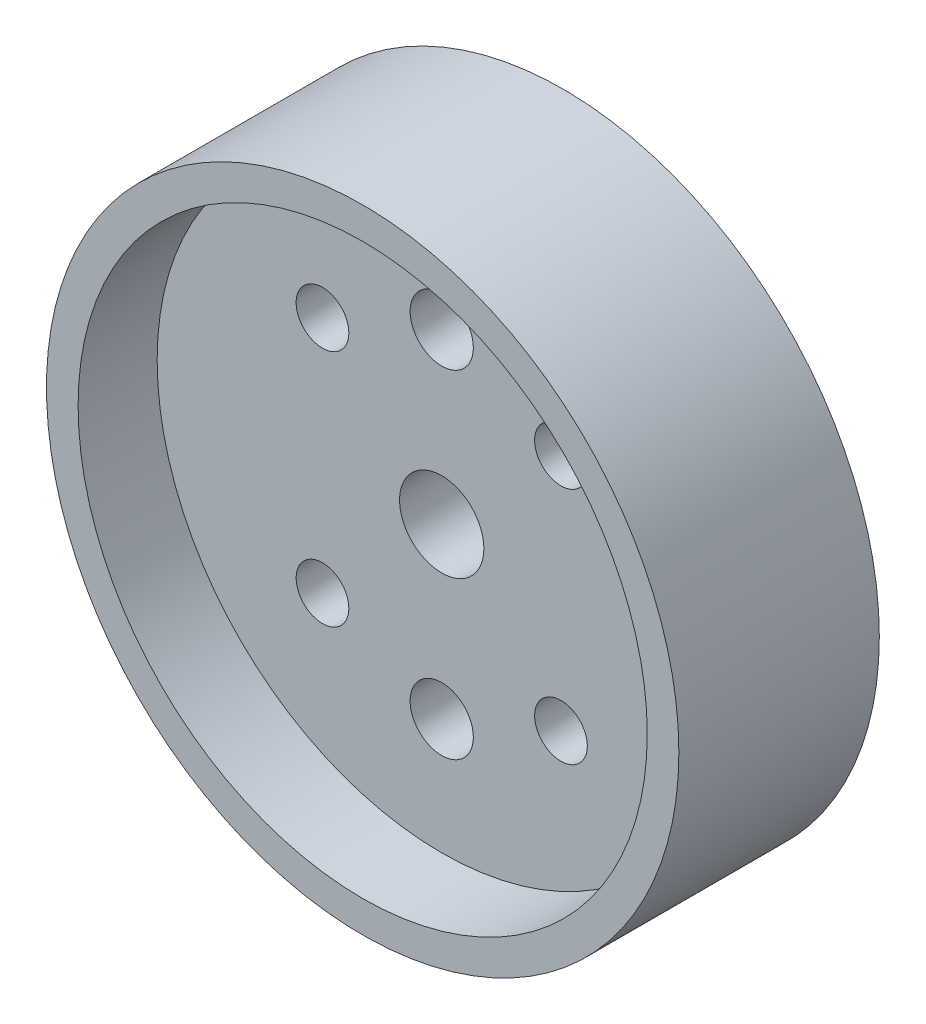
from build123d import *

# Parameters (mm, degrees)
ESBO_O1_R                = 30
RESSALTO_EXTRUS_O1_DEPTH = 19.02
ESBO_O2_R                = 26
CORTE_EXTRUS_O1_DEPTH    = 7
ESBO_O7_R                = 27
CORTE_EXTRUS_O4_DEPTH    = 7.5
ESBO_O13_R               = 3
ESBO_O13_R_2             = 2.5
CORTE_EXTRUS_O10_DEPTH   = 12.52
ESBO_O14_R               = 4
CORTE_EXTRUS_O11_DEPTH   = 12.52
ESBO_O16_R               = 5.25
ESBO_O16_R_2             = 4.5
CORTE_EXTRUS_O12_DEPTH   = 6


with BuildPart() as part:
    # Esboço1 → Ressalto-extrusão1 (new body)
    with BuildSketch(Plane.XY):
        Circle(ESBO_O1_R)
    extrude(amount=RESSALTO_EXTRUS_O1_DEPTH)

    # Esboço2 → Corte-extrusão1 (cut)
    with BuildSketch(Plane.XY.offset(19.02)):
        Circle(ESBO_O2_R)
    extrude(amount=-CORTE_EXTRUS_O1_DEPTH, mode=Mode.SUBTRACT)

    # Esboço7 → Corte-extrusão4 (cut)
    with BuildSketch(Plane.XY.offset(19.02)):
        Circle(ESBO_O7_R)
    extrude(amount=-CORTE_EXTRUS_O4_DEPTH, mode=Mode.SUBTRACT)

    # Esboço13 → Corte-extrusão10 (cut, through all)
    with BuildSketch(Plane.XY.offset(11.52)):
        with Locations((0, 16)):
            Circle(ESBO_O13_R)
        with Locations((0, -16)):
            Circle(ESBO_O13_R)
        with Locations((-11.313708499, 11.313708499)):
            Circle(ESBO_O13_R_2)
        with Locations((11.313708499, 11.313708499)):
            Circle(ESBO_O13_R_2)
        with Locations((-11.313708499, -11.313708499)):
            Circle(ESBO_O13_R_2)
        with Locations((11.313708499, -11.313708499)):
            Circle(ESBO_O13_R_2)
    extrude(amount=-CORTE_EXTRUS_O10_DEPTH, mode=Mode.SUBTRACT)

    # Esboço14 → Corte-extrusão11 (cut, through all)
    with BuildSketch(Plane.XY.offset(11.52)):
        Circle(ESBO_O14_R)
    extrude(amount=-CORTE_EXTRUS_O11_DEPTH, mode=Mode.SUBTRACT)

    # Esboço16 → Corte-extrusão12 (cut)
    with BuildSketch(Plane(origin=(0, 0, 0), x_dir=(-1, 0, 0), z_dir=(0, 0, -1))):
        with Locations((0, 16)):
            Circle(ESBO_O16_R)
        with Locations((0, -16)):
            Circle(ESBO_O16_R)
        with Locations((11.313708499, 11.313708499)):
            Circle(ESBO_O16_R_2)
        with Locations((-11.313708499, 11.313708499)):
            Circle(ESBO_O16_R_2)
        with Locations((-11.313708499, -11.313708499)):
            Circle(ESBO_O16_R_2)
        with Locations((11.313708499, -11.313708499)):
            Circle(ESBO_O16_R_2)
    extrude(amount=-CORTE_EXTRUS_O12_DEPTH, mode=Mode.SUBTRACT)


solid = part.part
